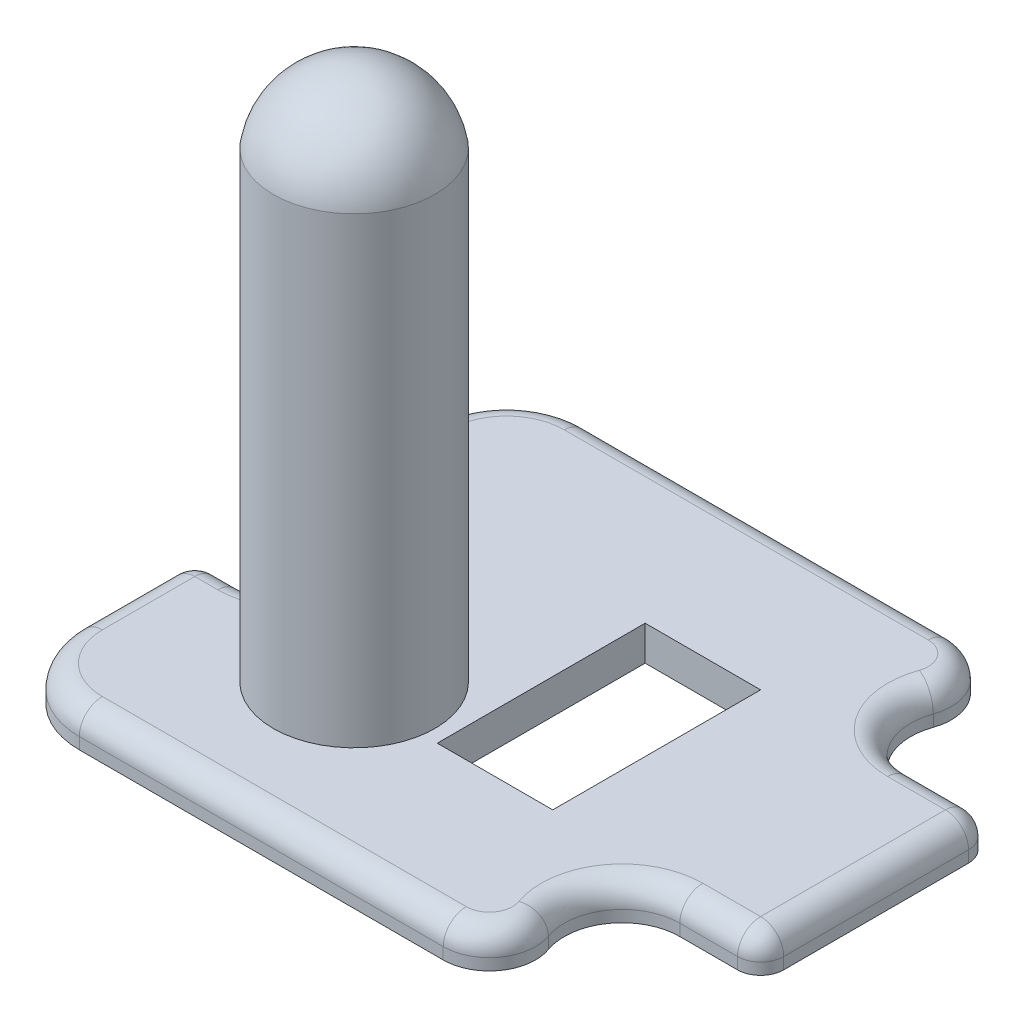
from build123d import *

# Parameters (mm, degrees)
SALIENTE_EXTRUIR1_DEPTH = 3
CORTAR_EXTRUIR1_REACH   = 5
CROQUIS2_W              = 10
CROQUIS2_H              = 18
CORTAR_EXTRUIR2_REACH   = 5
CROQUIS3_R              = 5
CROQUIS4_R              = 7
CROQUIS4_R_2            = 5
SALIENTE_EXTRUIR2_DEPTH = 40
CROQUIS5_R              = 7
SALIENTE_EXTRUIR3_DEPTH = 0.05
C_PULA1_FACE_RADIUS     = 7
C_PULA1_HEIGHT          = 6
REDONDEO1_R             = 2


with BuildPart() as part:
    # Croquis1 → Saliente-Extruir1 (new body)
    with BuildSketch(Plane(origin=(0, 155.4998128, 0), x_dir=(1, 0, 0), z_dir=(0, 1, 0))):
        with BuildLine():
            Line((1.881749032, 20.084971867), (1.881749032, 36.084971867))
            ThreePointArc((1.881749032, 36.084971867), (1.295962595, 37.499185429), (-0.118250968, 38.084971867))
            Line((-0.118250968, 38.084971867), (-5.118250968, 38.084971867))
            ThreePointArc((-5.118250968, 38.084971867), (-9.200733872, 40.198220521), (-9.832296176, 44.751638534))
            ThreePointArc((-9.832296176, 44.751638534), (-10.337546018, 48.394372944), (-13.603532342, 50.084971867))
            Line((-13.603532342, 50.084971867), (-45.118250968, 50.084971867))
            ThreePointArc((-45.118250968, 50.084971867), (-50.067998436, 48.034719335), (-52.118250968, 43.084971867))
            Line((-52.118250968, 43.084971867), (-52.118250968, 35.084971867))
            ThreePointArc((-52.118250968, 35.084971867), (-51.53246453, 33.670758305), (-50.118250968, 33.084971867))
            Line((-50.118250968, 33.084971867), (-48.118250968, 33.084971867))
            ThreePointArc((-48.118250968, 33.084971867), (-43.118250968, 28.084971867), (-48.118250968, 23.084971867))
            Line((-48.118250968, 23.084971867), (-50.118250968, 23.084971867))
            ThreePointArc((-50.118250968, 23.084971867), (-51.53246453, 22.499185429), (-52.118250968, 21.084971867))
            Line((-52.118250968, 21.084971867), (-52.118250968, 13.084971867))
            ThreePointArc((-52.118250968, 13.084971867), (-50.067998436, 8.135224399), (-45.118250968, 6.084971867))
            Line((-45.118250968, 6.084971867), (-13.603532342, 6.084971867))
            ThreePointArc((-13.603532342, 6.084971867), (-10.337546018, 7.77557079), (-9.832296176, 11.4183052))
            ThreePointArc((-9.832296176, 11.4183052), (-9.200733872, 15.971723213), (-5.118250968, 18.084971867))
            Line((-5.118250968, 18.084971867), (-0.118250968, 18.084971867))
            ThreePointArc((-0.118250968, 18.084971867), (1.295962595, 18.670758305), (1.881749032, 20.084971867))
        make_face()
    extrude(amount=SALIENTE_EXTRUIR1_DEPTH)

    # Croquis2 → Cortar-Extruir1 (cut, up to next)
    with BuildSketch(Plane(origin=(0, 158.4998128, 0), x_dir=(1, 0, 0), z_dir=(0, 1, 0)), mode=Mode.PRIVATE) as cortar_extruir1_sk1:
        with Locations((-22.118250968, 28.084971867)):
            Rectangle(CROQUIS2_W, CROQUIS2_H)
    cortar_extruir1_tool1 = extrude(cortar_extruir1_sk1.sketch, amount=-CORTAR_EXTRUIR1_REACH, mode=Mode.PRIVATE) & part.part
    add(cortar_extruir1_tool1.solids().sort_by_distance((-22.118251, 158.499813, -28.084972))[0], mode=Mode.SUBTRACT)

    # Croquis3 → Cortar-Extruir2 (cut, up to next)
    with BuildSketch(Plane(origin=(0, 158.4998128, 0), x_dir=(1, 0, 0), z_dir=(0, 1, 0)), mode=Mode.PRIVATE) as cortar_extruir2_sk1:
        with Locations((-35.318250968, 20.084971867)):
            Circle(CROQUIS3_R)
    cortar_extruir2_tool1 = extrude(cortar_extruir2_sk1.sketch, amount=-CORTAR_EXTRUIR2_REACH, mode=Mode.PRIVATE) & part.part
    add(cortar_extruir2_tool1.solids().sort_by_distance((-35.318251, 158.499813, -20.084972))[0], mode=Mode.SUBTRACT)

    # Croquis4 → Saliente-Extruir2 (add)
    with BuildSketch(Plane(origin=(0, 158.4998128, 0), x_dir=(1, 0, 0), z_dir=(0, 1, 0))):
        with Locations((-35.318250968, 20.084971867)):
            Circle(CROQUIS4_R)
        with Locations((-35.318250968, 20.084971867)):
            Circle(CROQUIS4_R_2, mode=Mode.SUBTRACT)
    extrude(amount=SALIENTE_EXTRUIR2_DEPTH)

    # Croquis5 → Saliente-Extruir3 (add)
    with BuildSketch(Plane(origin=(0, 198.4998128, 0), x_dir=(1, 0, 0), z_dir=(0, 1, 0))):
        with Locations((-35.318250968, 20.084971867)):
            Circle(CROQUIS5_R)
    extrude(amount=SALIENTE_EXTRUIR3_DEPTH)

    # C_pula1: a dome of height H over a round flat face of radius A is a cap of a sphere of radius (A * A + H * H) / (2 * H)
    c_pula1_r = (C_PULA1_FACE_RADIUS * C_PULA1_FACE_RADIUS + C_PULA1_HEIGHT * C_PULA1_HEIGHT) / (2 * C_PULA1_HEIGHT)
    c_pula1_base = Plane((-35.318250968, 198.5498128, -20.084971867), z_dir=(0, 1, 0))
    with Locations(c_pula1_base.offset(C_PULA1_HEIGHT - c_pula1_r)):
        c_pula1_ball = Sphere(c_pula1_r, mode=Mode.PRIVATE)
    add(split(c_pula1_ball, bisect_by=c_pula1_base, keep=Keep.TOP, mode=Mode.PRIVATE))

    # Redondeo1
    redondeo1_edges = [part.edges().sort_by_distance(p)[0] for p in [
        (1.295962595, 158.4998128, -37.499185429),
        (-2.618250968, 158.4998128, -38.084971867),
        (-9.200733872, 158.4998128, -40.198220521),
        (-10.337546018, 158.4998128, -48.394372944),
        (-29.360891655, 158.4998128, -50.084971867),
        (-50.067998436, 158.4998128, -48.034719335),
        (-52.118250968, 158.4998128, -39.084971867),
        (-51.53246453, 158.4998128, -33.670758305),
        (-49.118250968, 158.4998128, -33.084971867),
        (-43.118250968, 158.4998128, -28.084971867),
        (1.295962595, 158.4998128, -18.670758305),
        (-49.118250968, 158.4998128, -23.084971867),
        (-51.53246453, 158.4998128, -22.499185429),
        (-52.118250968, 158.4998128, -17.084971867),
        (-50.067998436, 158.4998128, -8.135224399),
        (-29.360891655, 158.4998128, -6.084971867),
        (-10.337546018, 158.4998128, -7.77557079),
        (-9.200733872, 158.4998128, -15.971723213),
        (-2.618250968, 158.4998128, -18.084971867),
        (1.881749032, 158.4998128, -28.084971867),
    ]]
    fillet(redondeo1_edges, radius=REDONDEO1_R)


solid = part.part
